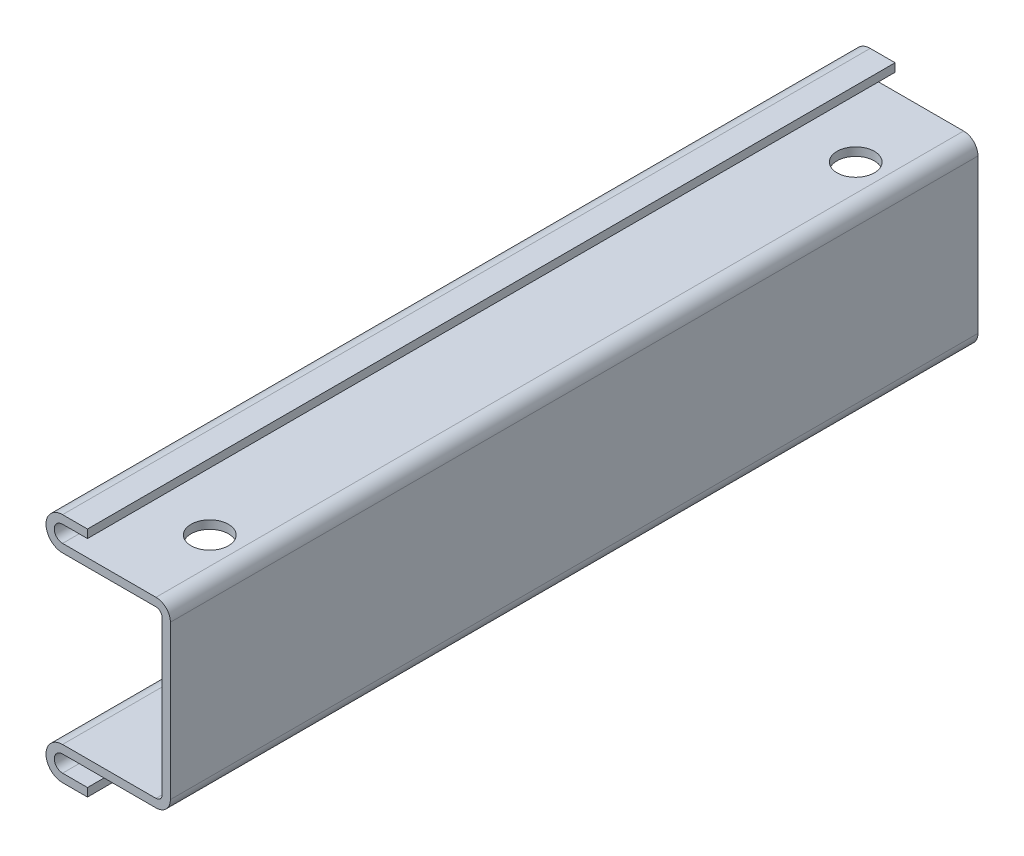
from build123d import *

# Parameters (mm, degrees)
EXTRUDE_1_DEPTH     = 97.4
SKETCH_2_R          = 2.25
CUT_EXTRUDE_1_DEPTH = 97.4


with BuildPart() as part:
    # 草图1 → 凸台-拉伸1 (new body)
    with BuildSketch(Plane.XY):
        with BuildLine():
            Line((-13, 0.7366), (-1.7366, 0.7366))
            ThreePointArc((-1.7366, 0.7366), (-1.215745145, 0.520854855), (-1, 0))
            Line((-1, 0), (-1, -18.5268))
            ThreePointArc((-1, -18.5268), (-1.215745145, -19.047654855), (-1.7366, -19.2634))
            Line((-1.7366, -19.2634), (-13, -19.2634))
            ThreePointArc((-13, -19.2634), (-15, -21.2634), (-13, -23.2634))
            Line((-13, -23.2634), (-10, -23.2634))
            Line((-10, -23.2634), (-10, -22.2634))
            Line((-10, -22.2634), (-13, -22.2634))
            ThreePointArc((-13, -22.2634), (-14, -21.2634), (-13, -20.2634))
            Line((-13, -20.2634), (-1.7366, -20.2634))
            ThreePointArc((-1.7366, -20.2634), (-0.508638364, -19.754761636), (0, -18.5268))
            Line((0, -18.5268), (0, 0))
            ThreePointArc((0, 0), (-0.508638364, 1.227961636), (-1.7366, 1.7366))
            Line((-1.7366, 1.7366), (-13, 1.7366))
            ThreePointArc((-13, 1.7366), (-14, 2.7366), (-13, 3.7366))
            Line((-13, 3.7366), (-10, 3.7366))
            Line((-10, 3.7366), (-10, 4.7366))
            Line((-10, 4.7366), (-13, 4.7366))
            ThreePointArc((-13, 4.7366), (-15, 2.7366), (-13, 0.7366))
        make_face()
    extrude(amount=EXTRUDE_1_DEPTH)

    # 草图2 → 切除-拉伸1 (cut)
    with BuildSketch(Plane.XZ.offset(20.2634)):
        with Locations((-5, 87.65)):
            Circle(SKETCH_2_R)
        with Locations((-5, 9.75)):
            Circle(SKETCH_2_R)
    extrude(amount=-CUT_EXTRUDE_1_DEPTH, mode=Mode.SUBTRACT)


solid = part.part
